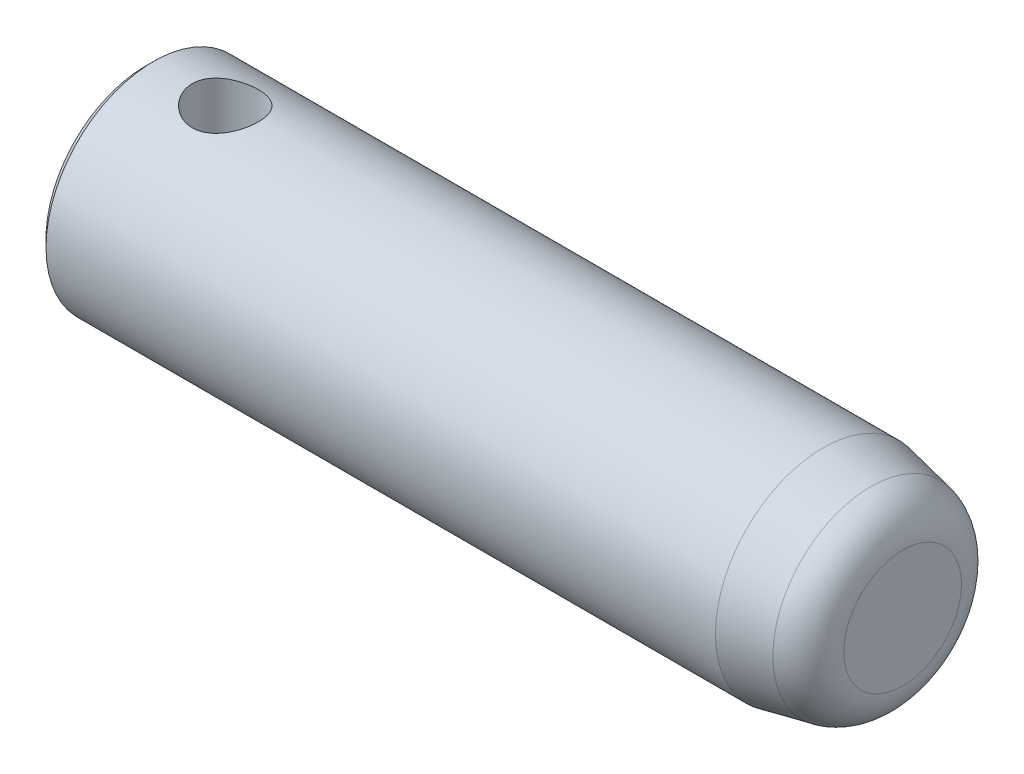
from build123d import *

# Parameters (mm, degrees)
SKETCH2_R               = 13.5
BOSS_EXTRUDE1_DEPTH     = 95
CHAMFER1_SIZE           = 10
CHAMFER1_SIZE2          = 2.034522994
FILLET1_R               = 5
CHAMFER2_SIZE           = 1
SKETCH3_R               = 4.15
CUT_EXTRUDE1_DEPTH      = 14.5
CUT_EXTRUDE1_DEPTH_BACK = 14.5


with BuildPart() as part:
    # Sketch2 → Boss-Extrude1 (new body)
    with BuildSketch(Plane(origin=(0, 0, 0), x_dir=(0, 0, -1), z_dir=(1, 0, 0))):
        Circle(SKETCH2_R)
    extrude(amount=BOSS_EXTRUDE1_DEPTH)

    # Chamfer1
    chamfer1_edges = [part.edges().sort_by_distance(p)[0] for p in [
        (95, 0, 13.5),
    ]]
    chamfer1_side = [part.faces().sort_by_distance(p)[0] for p in [
        (47.5, 0, 13.5),
    ]]
    chamfer(chamfer1_edges, length=CHAMFER1_SIZE, length2=CHAMFER1_SIZE2, reference=chamfer1_side[0])

    # Fillet1
    fillet1_edges = [part.edges().sort_by_distance(p)[0] for p in [
        (95, 0, 11.465477006),
    ]]
    fillet(fillet1_edges, radius=FILLET1_R)

    # Chamfer2
    chamfer2_edges = [part.edges().sort_by_distance(p)[0] for p in [
        (0, 0, 13.5),
    ]]
    chamfer(chamfer2_edges, length=CHAMFER2_SIZE)

    # Sketch3 → Cut-Extrude1 (cut, two sides)
    with BuildSketch(Plane(origin=(0, 0, 0), x_dir=(1, 0, 0), z_dir=(0, 1, 0))) as cut_extrude1_sk:
        with Locations((10, 0)):
            Circle(SKETCH3_R)
    extrude(amount=CUT_EXTRUDE1_DEPTH, mode=Mode.SUBTRACT)
    extrude(cut_extrude1_sk.sketch, amount=-CUT_EXTRUDE1_DEPTH_BACK, mode=Mode.SUBTRACT)


solid = part.part
